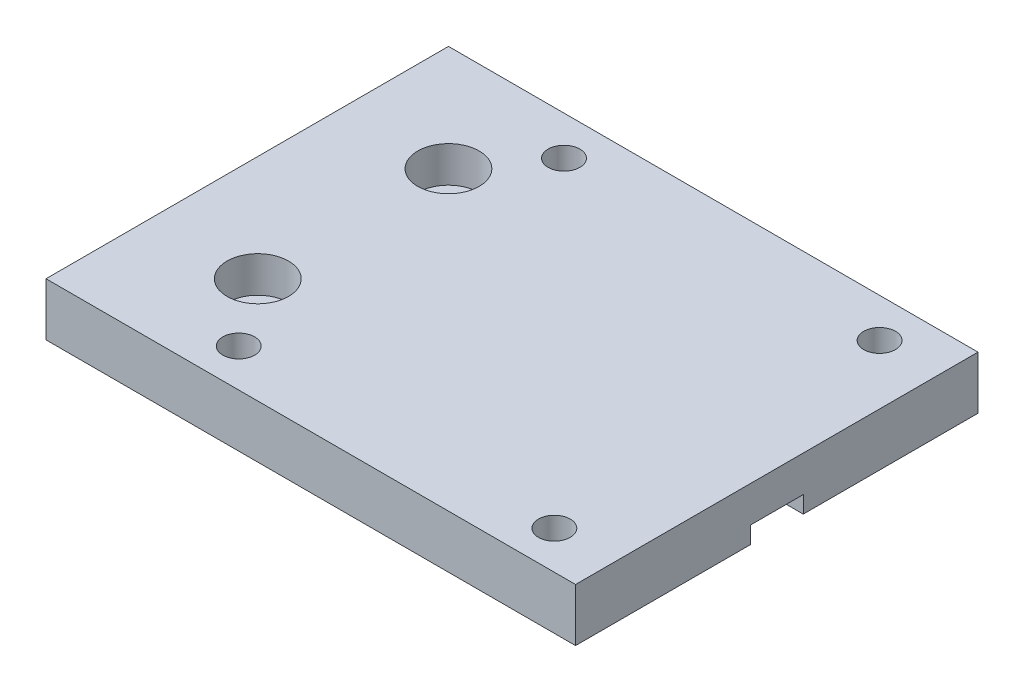
from build123d import *

# Parameters (mm, degrees)
SKETCH1_W           = 63.5
SKETCH1_H           = 48.26
BOSS_EXTRUDE1_DEPTH = 6.35
SKETCH2_R           = 3.683
CUT_EXTRUDE1_DEPTH  = 4.318
SKETCH3_R           = 2.159
CUT_EXTRUDE2_DEPTH  = 4.318
SKETCH5_W           = 46.99
SKETCH5_H           = 6.35
CUT_EXTRUDE3_DEPTH  = 2.032
SKETCH4_R           = 1.905
CUT_EXTRUDE4_DEPTH  = 14.732


with BuildPart() as part:
    # Sketch1 → Boss-Extrude1 (new body)
    with BuildSketch(Plane(origin=(0, 0, 0), x_dir=(1, 0, 0), z_dir=(0, 1, 0))):
        Rectangle(SKETCH1_W, SKETCH1_H)
    extrude(amount=-BOSS_EXTRUDE1_DEPTH)

    # Sketch2 → Cut-Extrude1 (cut)
    with BuildSketch(Plane(origin=(0, 0, 0), x_dir=(1, 0, 0), z_dir=(0, 1, 0))):
        with Locations((-19.05, 11.43)):
            Circle(SKETCH2_R)
    cut_extrude1 = extrude(amount=-CUT_EXTRUDE1_DEPTH, mode=Mode.SUBTRACT)

    # Sketch3 → Cut-Extrude2 (cut)
    with BuildSketch(Plane(origin=(0, -4.318, 0), x_dir=(1, 0, 0), z_dir=(0, 1, 0))):
        with Locations((-19.05, 11.43)):
            Circle(SKETCH3_R)
    cut_extrude2 = extrude(amount=-CUT_EXTRUDE2_DEPTH, mode=Mode.SUBTRACT)

    # Sketch5 → Cut-Extrude3 (cut)
    with BuildSketch(Plane.XZ.offset(6.35)):
        with Locations((8.255, 0)):
            Rectangle(SKETCH5_W, SKETCH5_H)
    extrude(amount=-CUT_EXTRUDE3_DEPTH, mode=Mode.SUBTRACT)

    # Sketch4 → Cut-Extrude4 (cut)
    with BuildSketch(Plane(origin=(0, 0, 0), x_dir=(1, 0, 0), z_dir=(0, 1, 0))):
        with Locations((-13.208, -19.558)):
            Circle(SKETCH4_R)
        with Locations((-13.208, 19.442)):
            Circle(SKETCH4_R)
        with Locations((24.638, -19.558)):
            Circle(SKETCH4_R)
        with Locations((24.638, 19.442)):
            Circle(SKETCH4_R)
    extrude(amount=-CUT_EXTRUDE4_DEPTH, mode=Mode.SUBTRACT)

    # Mirror1: Cut-Extrude1, Cut-Extrude2 across plane
    add(cut_extrude1.mirror(Plane.XY), mode=Mode.SUBTRACT)
    add(cut_extrude2.mirror(Plane.XY), mode=Mode.SUBTRACT)


solid = part.part
